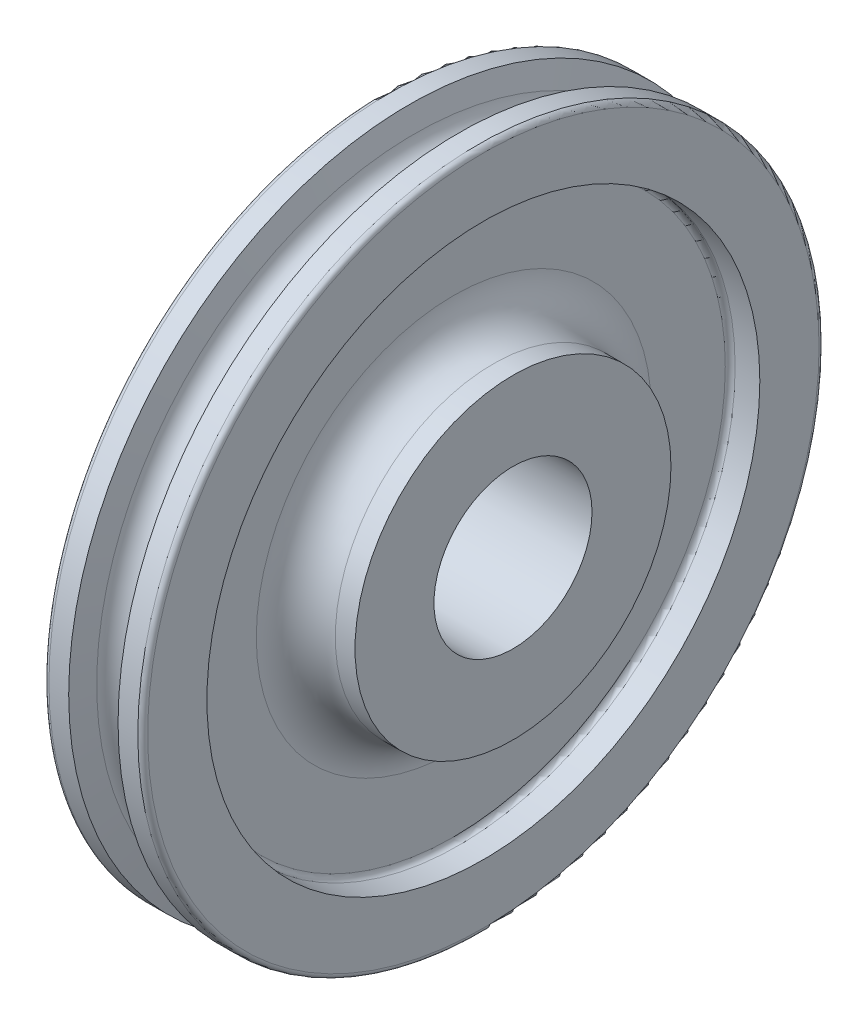
from build123d import *

# Parameters (mm, degrees)
SKETCH2_R          = 25.4127
CUT_EXTRUDE1_DEPTH = 51.8


with BuildPart() as part:
    # Sketch1 → Revolve1 (revolve)
    with BuildSketch(Plane.XY, mode=Mode.PRIVATE) as revolve1_sk:
        with BuildLine():
            Line((6.35, 87.3125), (6.35, 63.5))
            ThreePointArc((6.35, 63.5), (10.069743879, 54.519743879), (19.05, 50.8))
            Line((19.05, 50.8), (25.4, 50.8))
            Line((25.4, 50.8), (25.4, 0))
            Line((25.4, 0), (-25.4, 0))
            Line((-25.4, 0), (-25.4, 50.8))
            Line((-25.4, 50.8), (-19.05, 50.8))
            ThreePointArc((-19.05, 50.8), (-10.069743879, 54.519743879), (-6.35, 63.5))
            Line((-6.35, 63.5), (-6.35, 87.3125))
            ThreePointArc((-6.35, 87.3125), (-6.814967985, 88.435032015), (-7.9375, 88.9))
            Line((-7.9375, 88.9), (-15.875, 88.9))
            Line((-15.875, 88.9), (-15.875, 107.95))
            ThreePointArc((-15.875, 107.95), (-15.410032015, 109.072532015), (-14.2875, 109.5375))
            Line((-14.2875, 109.5375), (-7.9375, 109.5375))
            Line((-7.9375, 109.5375), (-6.271845407, 102.194295494))
            ThreePointArc((-6.271845407, 102.194295494), (0, 96.8375), (6.271845407, 102.194295494))
            Line((6.271845407, 102.194295494), (7.9375, 109.5375))
            Line((7.9375, 109.5375), (14.2875, 109.5375))
            ThreePointArc((14.2875, 109.5375), (15.410032015, 109.072532015), (15.875, 107.95))
            Line((15.875, 107.95), (15.875, 88.9))
            Line((15.875, 88.9), (7.9375, 88.9))
            ThreePointArc((7.9375, 88.9), (6.814967985, 88.435032015), (6.35, 87.3125))
        make_face()
    revolve(revolve1_sk.sketch.rotate(Axis((25.4, 0, 0), (-1, 0, 0)), 90), axis=Axis((25.4, 0, 0), (-1, 0, 0)))  # turned: the seam where the file's is

    # Sketch2 → Cut-Extrude1 (cut, through all)
    with BuildSketch(Plane(origin=(25.4, 0, 0), x_dir=(0, 0, -1), z_dir=(1, 0, 0))):
        Circle(SKETCH2_R)
    extrude(amount=-CUT_EXTRUDE1_DEPTH, mode=Mode.SUBTRACT)


solid = part.part
